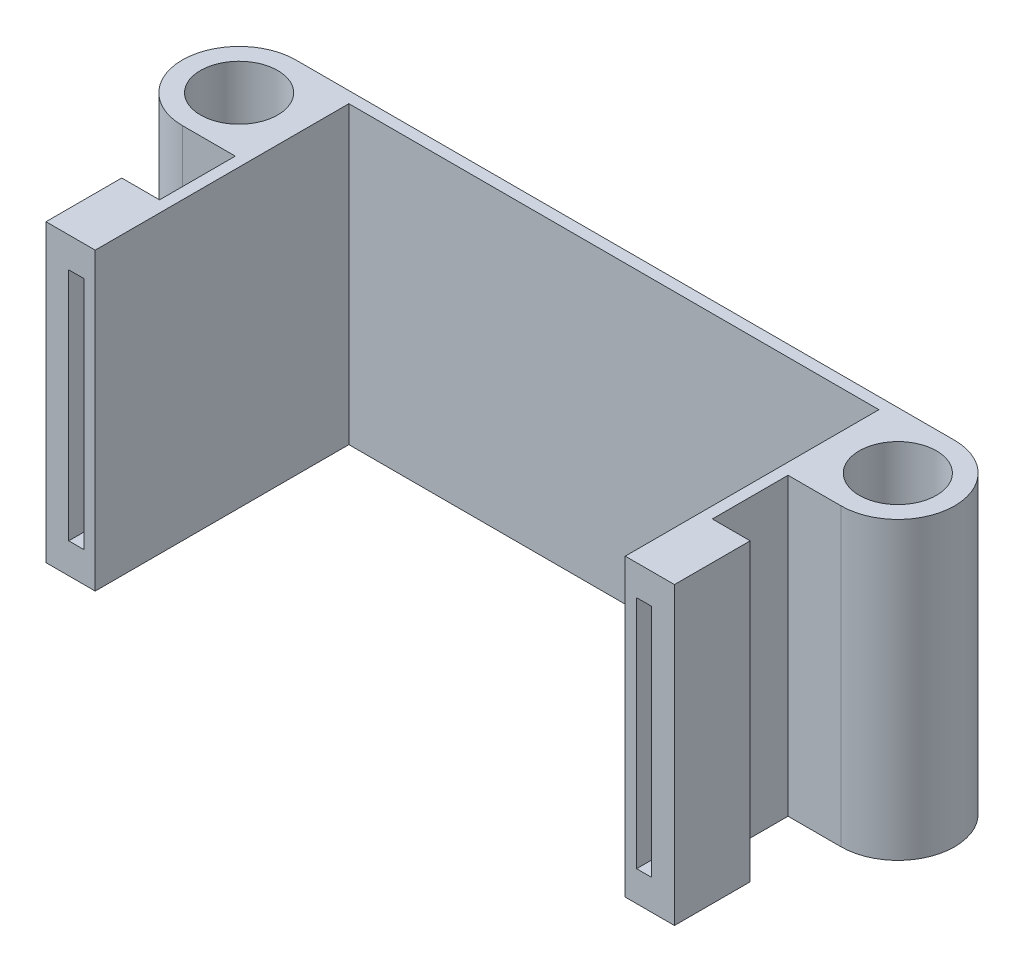
from build123d import *

# Parameters (mm, degrees)
SKETCH1_R           = 2.55
BOSS_EXTRUDE2_DEPTH = 19.5
SKETCH2_W           = 1
SKETCH2_H           = 15.5
CUT_EXTRUDE1_DEPTH  = 5


with BuildPart() as part:
    # Sketch1 → Boss-Extrude2 (new body)
    with BuildSketch(Plane(origin=(0, 0, 0), x_dir=(1, 0, 0), z_dir=(0, 1, 0))):
        with BuildLine():
            ThreePointArc((0, 3.75), (-3.75, 0), (0, -3.75))
            Line((0, -3.75), (3.5, -3.75))
            Line((3.5, -3.75), (3.5, -8.75))
            Line((3.5, -8.75), (1, -8.75))
            Line((1, -8.75), (1, -13.75))
            Line((1, -13.75), (4.25, -13.75))
            Line((4.25, -13.75), (4.25, 3))
            Line((4.25, 3), (39.25, 3))
            Line((39.25, 3), (39.25, -13.75))
            Line((39.25, -13.75), (42.5, -13.75))
            Line((42.5, -13.75), (42.5, -8.75))
            Line((42.5, -8.75), (40, -8.75))
            Line((40, -8.75), (40, -3.75))
            Line((40, -3.75), (43.5, -3.75))
            ThreePointArc((43.5, -3.75), (47.25, 0), (43.5, 3.75))
            Line((43.5, 3.75), (0, 3.75))
        make_face()
        Circle(SKETCH1_R, mode=Mode.SUBTRACT)
        with Locations((43.5, 0)):
            Circle(SKETCH1_R, mode=Mode.SUBTRACT)
    extrude(amount=BOSS_EXTRUDE2_DEPTH)

    # Sketch2 → Cut-Extrude1 (cut)
    with BuildSketch(Plane.XY.offset(13.75)):
        with Locations((3, 9.75)):
            Rectangle(SKETCH2_W, SKETCH2_H)
        with Locations((40.5, 9.75)):
            Rectangle(SKETCH2_W, SKETCH2_H)
    extrude(amount=-CUT_EXTRUDE1_DEPTH, mode=Mode.SUBTRACT)


solid = part.part
